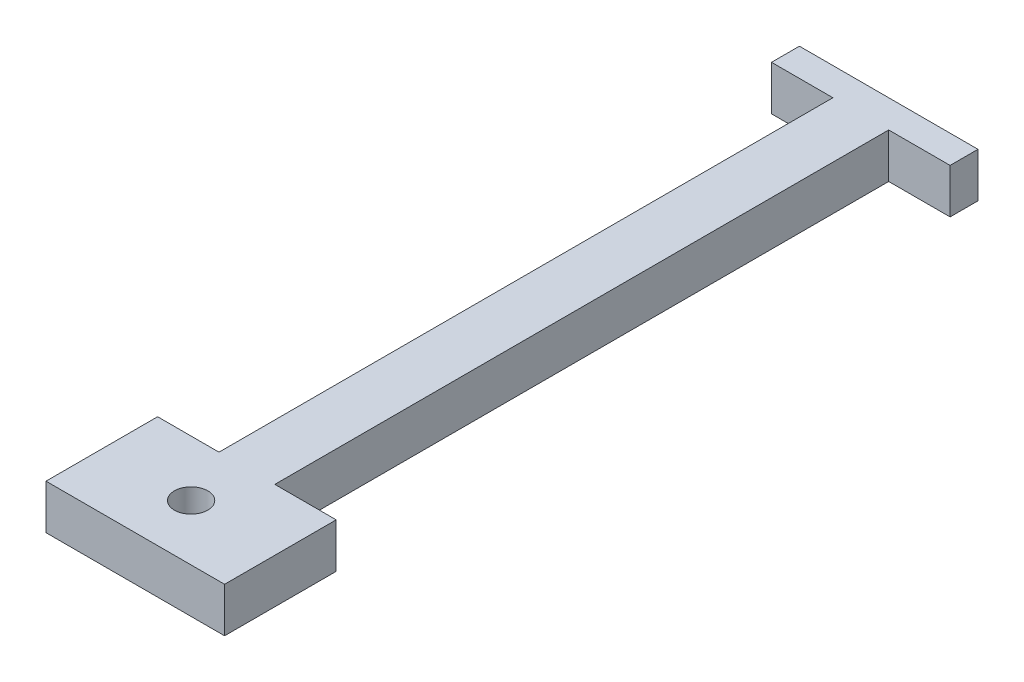
from build123d import *

# Parameters (mm, degrees)
BOSS_EXTRUDE1_DEPTH = 4
SKETCH2_W           = 16
SKETCH2_H           = 4
BOSS_EXTRUDE2_DEPTH = 10
SKETCH3_R           = 1.5
CUT_EXTRUDE1_DEPTH  = 10


with BuildPart() as part:
    # Sketch1 → Boss-Extrude1 (new body)
    with BuildSketch(Plane(origin=(0, 0, 0), x_dir=(1, 0, 0), z_dir=(0, 1, 0))):
        Polygon((8, 57.5), (-8, 57.5), (-8, 55), (-2.5, 55), (-2.5, 0), (2.5, 0), (2.5, 55), (8, 55), align=None)
    extrude(amount=BOSS_EXTRUDE1_DEPTH)

    # Sketch2 → Boss-Extrude2 (add)
    with BuildSketch(Plane.XY):
        with Locations((0, 2)):
            Rectangle(SKETCH2_W, SKETCH2_H)
    extrude(amount=BOSS_EXTRUDE2_DEPTH)

    # Sketch3 → Cut-Extrude1 (cut)
    with BuildSketch(Plane(origin=(0, 4, 0), x_dir=(1, 0, 0), z_dir=(0, 1, 0))):
        with Locations((0, -5)):
            Circle(SKETCH3_R)
    extrude(amount=-CUT_EXTRUDE1_DEPTH, mode=Mode.SUBTRACT)


solid = part.part
